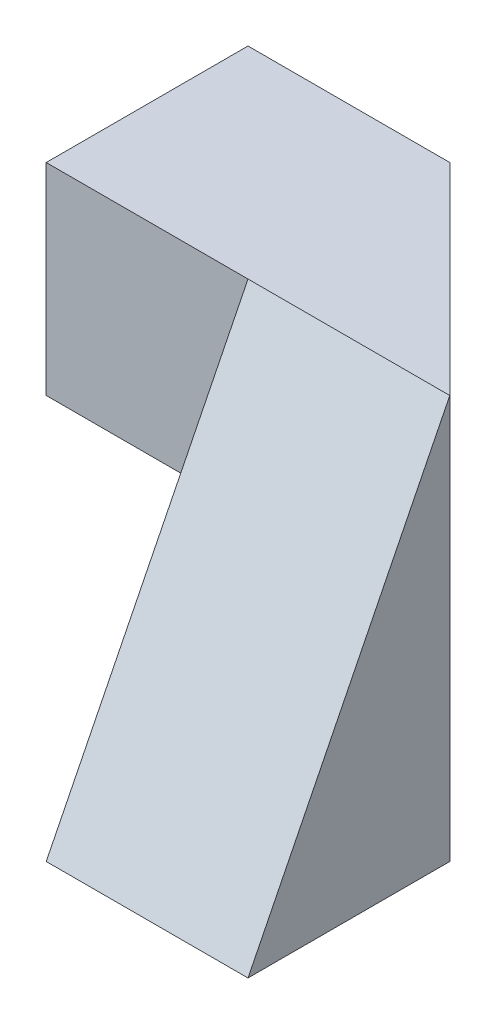
from build123d import *

# Parameters (mm, degrees)
SKETCH1_W           = 40
SKETCH1_H           = 40
BOSS_EXTRUDE1_DEPTH = 40
SKETCH2_W           = 20
SKETCH2_H           = 20
CUT_EXTRUDE1_DEPTH  = 40
CUT_EXTRUDE2_DEPTH  = 40
SKETCH4_W           = 20
SKETCH4_H           = 20
CUT_EXTRUDE3_DEPTH  = 40
CUT_EXTRUDE4_DEPTH  = 40


with BuildPart() as part:
    # Sketch1 → Boss-Extrude1 (new body)
    with BuildSketch(Plane.XY):
        with Locations((20, 20)):
            Rectangle(SKETCH1_W, SKETCH1_H)
    extrude(amount=BOSS_EXTRUDE1_DEPTH)

    # Sketch2 → Cut-Extrude1 (cut)
    with BuildSketch(Plane.XY.offset(40)):
        with Locations((10, 10)):
            Rectangle(SKETCH2_W, SKETCH2_H)
    extrude(amount=-CUT_EXTRUDE1_DEPTH, mode=Mode.SUBTRACT)

    # Sketch3 → Cut-Extrude2 (cut)
    with BuildSketch(Plane.ZY):
        Polygon((20, 40), (40, 0), (40, 40), align=None)
    extrude(amount=-CUT_EXTRUDE2_DEPTH, mode=Mode.SUBTRACT)

    # Sketch4 → Cut-Extrude3 (cut)
    with BuildSketch(Plane(origin=(0, 0, 0), x_dir=(-1, 0, 0), z_dir=(0, -1, 0))):
        with Locations((-10, -30)):
            Rectangle(SKETCH4_W, SKETCH4_H)
    extrude(amount=-CUT_EXTRUDE3_DEPTH, mode=Mode.SUBTRACT)

    # Sketch5 → Cut-Extrude4 (cut)
    with BuildSketch(Plane(origin=(0, 40, 0), x_dir=(1, 0, 0), z_dir=(0, 1, 0))):
        Polygon((20, 0), (40, -20), (40, 0), align=None)
    extrude(amount=-CUT_EXTRUDE4_DEPTH, mode=Mode.SUBTRACT)


solid = part.part
